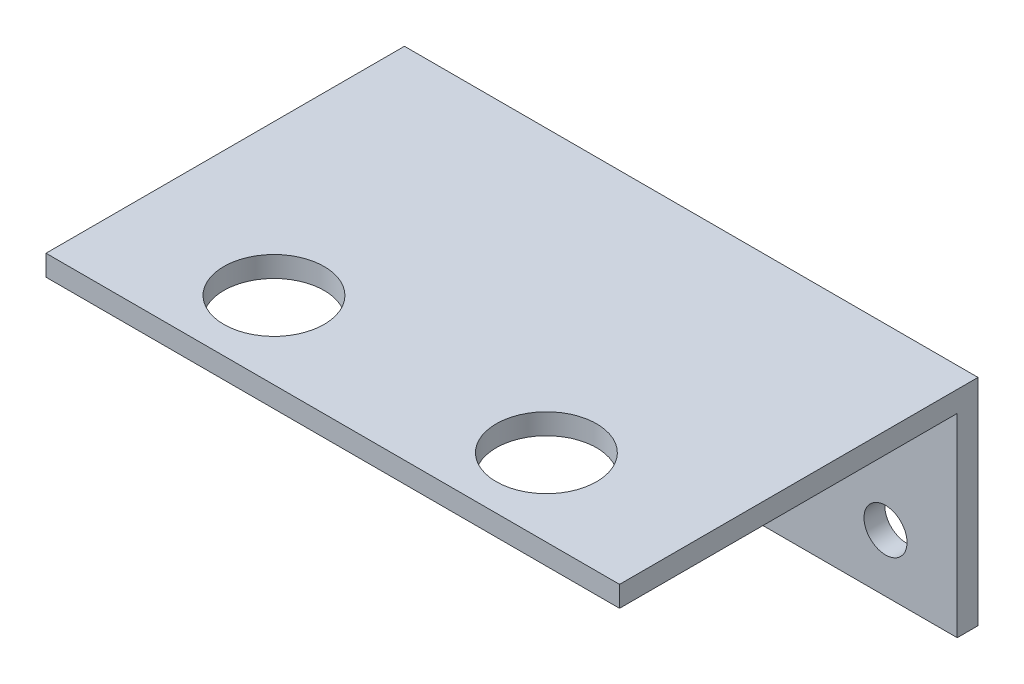
from build123d import *

# Parameters (mm, degrees)
SKETCH1_W           = 40
SKETCH1_H           = 15
BOSS_EXTRUDE1_DEPTH = 1.45
SKETCH2_W           = 40
SKETCH2_H           = 1.45
BOSS_EXTRUDE2_DEPTH = 23.55
SKETCH3_R           = 1.5
CUT_EXTRUDE1_DEPTH  = 1.45
SKETCH4_R           = 3.5
CUT_EXTRUDE2_DEPTH  = 1.45


with BuildPart() as part:
    # Sketch1 → Boss-Extrude1 (new body)
    with BuildSketch(Plane.XY):
        Rectangle(SKETCH1_W, SKETCH1_H)
    extrude(amount=BOSS_EXTRUDE1_DEPTH)

    # Sketch2 → Boss-Extrude2 (add)
    with BuildSketch(Plane.XY.offset(1.45)):
        with Locations((0, 6.775)):
            Rectangle(SKETCH2_W, SKETCH2_H)
    extrude(amount=BOSS_EXTRUDE2_DEPTH)

    # Sketch3 → Cut-Extrude1 (cut)
    with BuildSketch(Plane.XY.offset(1.45)):
        with Locations((-15, -3.5)):
            Circle(SKETCH3_R)
    cut_extrude1 = extrude(amount=-CUT_EXTRUDE1_DEPTH, mode=Mode.SUBTRACT)

    # Mirror1: Cut-Extrude1 across plane
    add(cut_extrude1.mirror(Plane(origin=(0, 0, 0), x_dir=(0, 0, 1), z_dir=(1, 0, 0))), mode=Mode.SUBTRACT)

    # Sketch4 → Cut-Extrude2 (cut)
    with BuildSketch(Plane(origin=(0, 7.5, 0), x_dir=(1, 0, 0), z_dir=(0, 1, 0))):
        with Locations((-9.5, -19.6)):
            Circle(SKETCH4_R)
    cut_extrude2 = extrude(amount=-CUT_EXTRUDE2_DEPTH, mode=Mode.SUBTRACT)

    # Mirror2: Cut-Extrude2 across plane
    add(cut_extrude2.mirror(Plane(origin=(0, 0, 0), x_dir=(0, 0, 1), z_dir=(1, 0, 0))), mode=Mode.SUBTRACT)


solid = part.part
